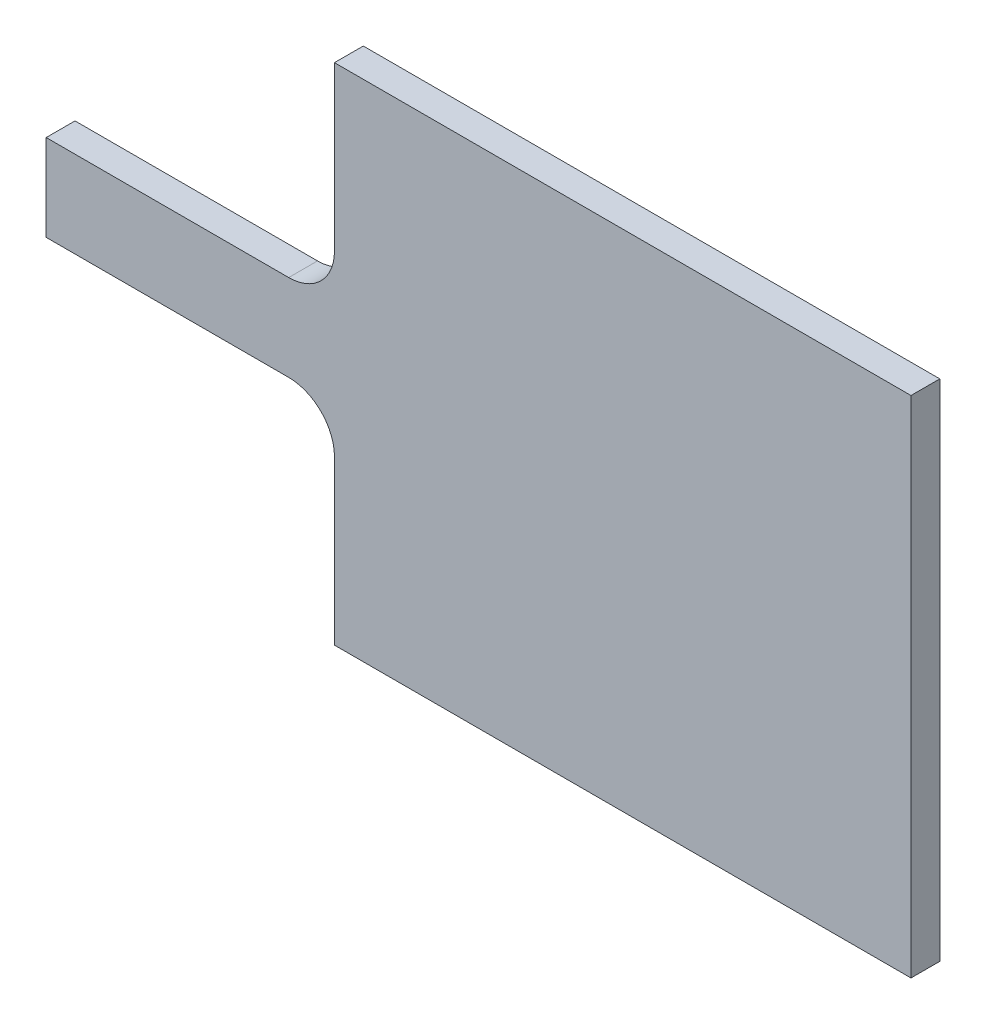
from build123d import *

# Parameters (mm, degrees)
BOSS_EXTRUDE1_DEPTH = 1


with BuildPart() as part:
    # Sketch1 → Boss-Extrude1 (new body)
    with BuildSketch(Plane.XY):
        with BuildLine():
            Line((0, 11.8375), (0, 17.5))
            Line((0, 17.5), (20, 17.5))
            Line((20, 17.5), (20, 0))
            Line((20, 0), (0, 0))
            Line((0, 0), (0, 5.6625))
            ThreePointArc((0, 5.6625), (-0.464967985, 6.785032015), (-1.5875, 7.25))
            Line((-1.5875, 7.25), (-10, 7.25))
            Line((-10, 7.25), (-10, 10.25))
            Line((-10, 10.25), (-1.5875, 10.25))
            ThreePointArc((-1.5875, 10.25), (-0.464967985, 10.714967985), (0, 11.8375))
        make_face()
    extrude(amount=BOSS_EXTRUDE1_DEPTH)


solid = part.part
